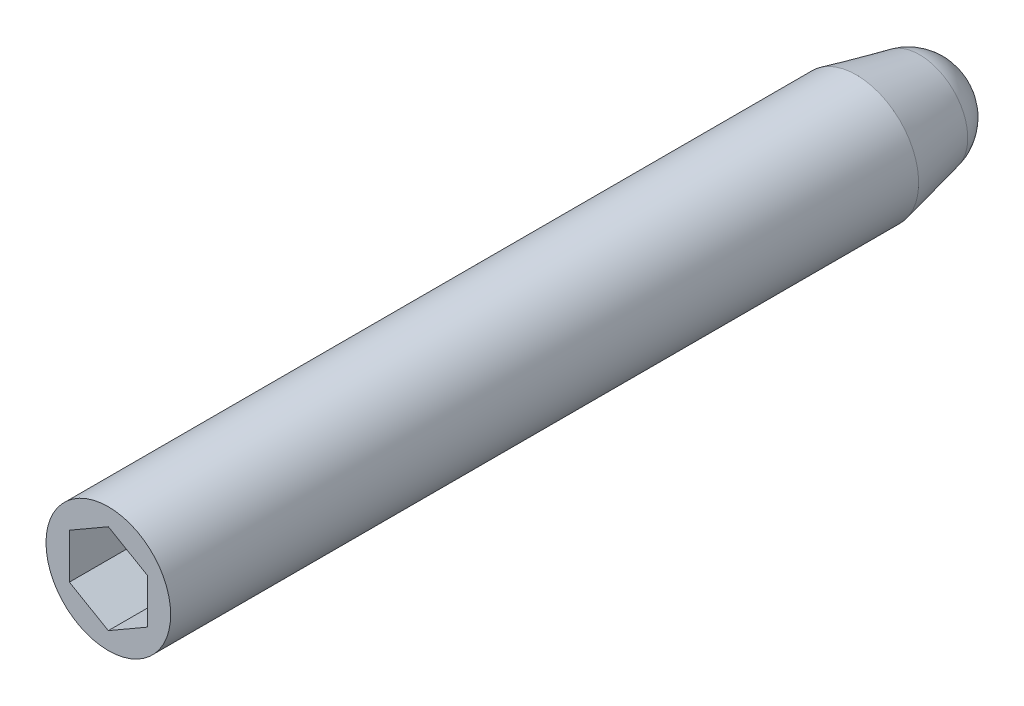
from build123d import *

# Parameters (mm, degrees)
SKETCH1_R           = 3.175
BOSS_EXTRUDE1_DEPTH = 38.1
CUT_EXTRUDE1_DEPTH  = 3.175


with BuildPart() as part:
    # Sketch1 → Boss-Extrude1 (new body)
    with BuildSketch(Plane.XY):
        Circle(SKETCH1_R)
    extrude(amount=BOSS_EXTRUDE1_DEPTH)

    # Sketch2 → Cut-Extrude1 (cut)
    with BuildSketch(Plane.XY.offset(38.1)):
        Polygon((0, 2.291358881), (-1.984375, 1.14567944), (-1.984375, -1.14567944), (0, -2.291358881), (1.984375, -1.14567944), (1.984375, 1.14567944), align=None)
    extrude(amount=-CUT_EXTRUDE1_DEPTH, mode=Mode.SUBTRACT)

    # Sketch3 → Revolve1 (revolve)
    with BuildSketch(Plane(origin=(0, 0, 0), x_dir=(1, 0, 0), z_dir=(0, 1, 0))):
        with BuildLine():
            Line((-3.175, 0), (-2.453715979, 3.222429819))
            ThreePointArc((-2.453715979, 3.222429819), (-1.567259814, 4.600861122), (0, 5.08))
            Line((0, 5.08), (0, 0))
            Line((0, 0), (-3.175, 0))
        make_face()
    revolve(axis=Axis((0, 0, -5.08), (0, 0, 1)))


solid = part.part
